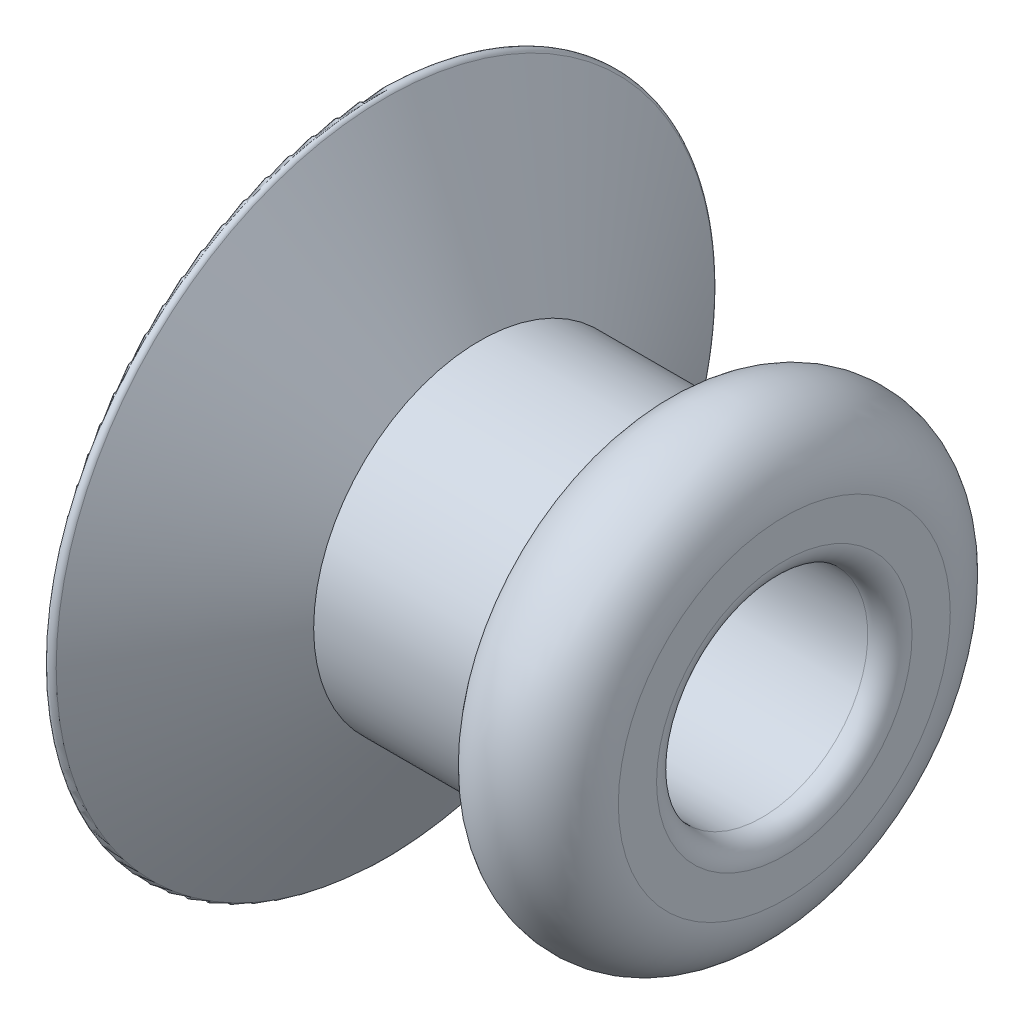
from build123d import *


with BuildPart() as part:
    # Эскиз2 → Повернуть1 (revolve)
    with BuildSketch(Plane.XY):
        with BuildLine():
            Line((3.498076211, -0.95446582), (0.2, -0.95446582))
            ThreePointArc((0.2, -0.95446582), (0.058578644, -1.013044464), (0, -1.15446582))
            Line((0, -1.15446582), (0, -2.95))
            ThreePointArc((0, -2.95), (0.037059048, -2.998296291), (0.09330127, -2.975))
            Line((0.09330127, -2.975), (0.944892917, -1.5))
            Line((0.944892917, -1.5), (2.5, -1.5))
            ThreePointArc((2.5, -1.5), (3.099038106, -2.099038106), (3.698076211, -1.5))
            Line((3.698076211, -1.5), (3.698076211, -1.15446582))
            ThreePointArc((3.698076211, -1.15446582), (3.639497568, -1.013044464), (3.498076211, -0.95446582))
        make_face()
    revolve(axis=Axis((0, 0, 0), (1, 0, 0)))


solid = part.part
